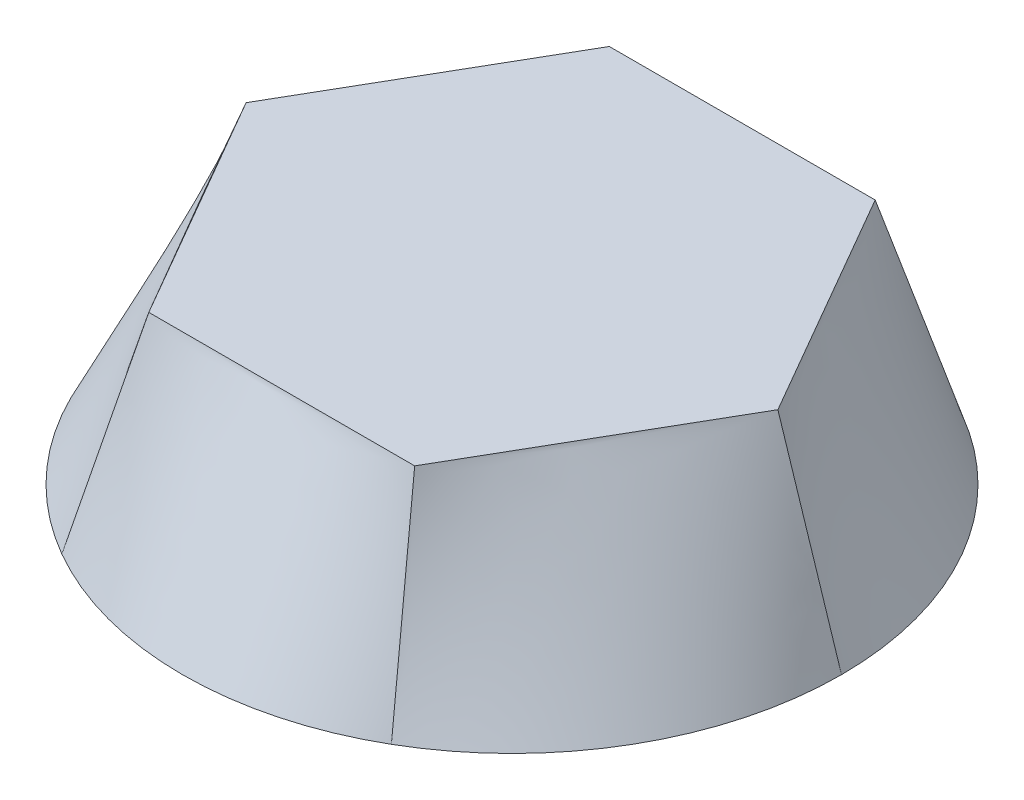
from build123d import *


with BuildPart() as part:
    # Sketch1 for Loft1 → Loft1 section 0
    with BuildSketch(Plane(origin=(0, 0, 0), x_dir=(1, 0, 0), z_dir=(0, 1, 0))):
        with BuildLine():
            # circular arc as an exact rational Bezier (weights 1, cos(half-angle), 1)
            Bezier((25, 0), (25.000000001, 14.43375673), (12.5, 21.650635095), weights=[1, 0.866025404, 1])
            Bezier((12.5, 21.650635095), (0, 28.867513459), (-12.5, 21.650635095), weights=[1, 0.866025404, 1])
            Bezier((-12.5, 21.650635095), (-25.000000001, 14.43375673), (-25, 0), weights=[1, 0.866025404, 1])
            Bezier((-25, 0), (-25.000000001, -14.43375673), (-12.5, -21.650635095), weights=[1, 0.866025404, 1])
            Bezier((-12.5, -21.650635095), (0, -28.867513459), (12.5, -21.650635095), weights=[1, 0.866025404, 1])
            Bezier((12.5, -21.650635095), (25.000000001, -14.43375673), (25, 0), weights=[1, 0.866025404, 1])
        make_face()
    # Sketch2 → Loft1 section 1
    with BuildSketch(Plane(origin=(0, 15, 0), x_dir=(1, 0, 0), z_dir=(0, 1, 0))):
        Polygon((20.172526377, 0), (10.086263189, 17.469920301), (-10.086263189, 17.469920301), (-20.172526377, 0), (-10.086263189, -17.469920301), (10.086263189, -17.469920301), align=None)
    loft()


solid = part.part
